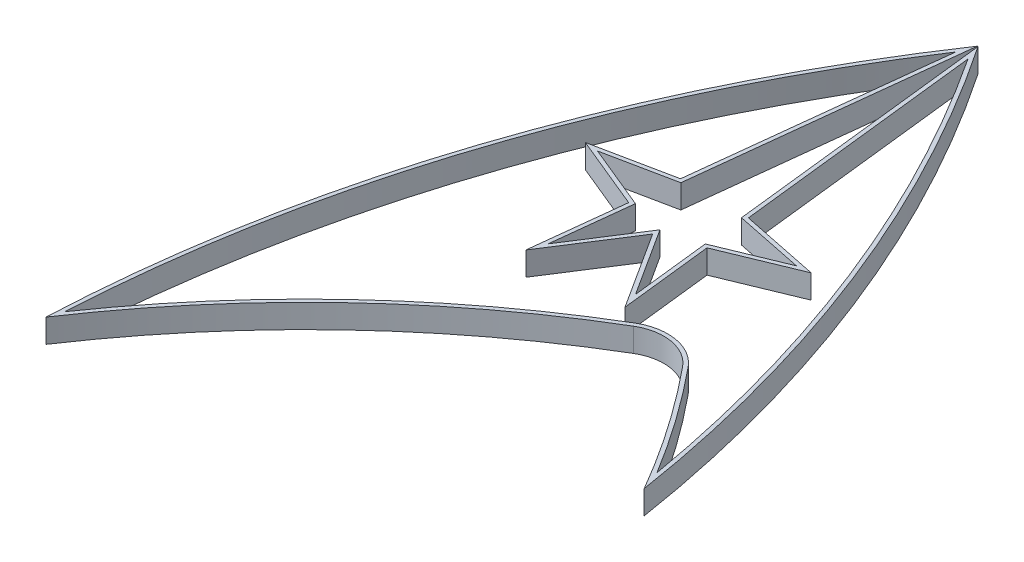
from build123d import *

# Parameters (mm, degrees)
BOSS_EXTRUDE1_DEPTH = 2.4


with BuildPart() as part:
    # Sketch2 → Boss-Extrude1 (new body)
    with BuildSketch(Plane(origin=(0, 0, 0), x_dir=(1, 0, 0), z_dir=(0, 1, 0))):
        with BuildLine():
            Line((25.28293267, 77.245611288), (22.241395548, 50.202851698))
            Line((22.241395548, 50.202851698), (15.224426897, 48.764665996))
            Line((15.224426897, 48.764665996), (21.775683691, 46.062138205))
            Line((21.775683691, 46.062138205), (20.878911595, 38.088803933))
            Line((20.878911595, 38.088803933), (25.3187138, 45.004925816))
            Line((25.3187138, 45.004925816), (29.758516004, 38.088803933))
            Line((29.758516004, 38.088803933), (28.861743908, 46.062138205))
            Line((28.861743908, 46.062138205), (35.413000702, 48.764665996))
            Line((35.413000702, 48.764665996), (28.396032051, 50.202851698))
            Line((28.396032051, 50.202851698), (25.354494929, 77.245611288))
            ThreePointArc((25.354494929, 77.245611288), (39.364716338, 50.558630658), (47.260701361, 21.470236759))
            ThreePointArc((47.260701361, 21.470236759), (43.131494569, 27.98329808), (38.487800716, 34.14011738))
            ThreePointArc((38.487800716, 34.14011738), (35.669967354, 35.788554713), (32.458155801, 35.203920598))
            ThreePointArc((32.458155801, 35.203920598), (15.517725775, 22.41503931), (1.838377838, 6.185156559))
            ThreePointArc((1.838377838, 6.185156559), (8.663390647, 43.331109422), (25.28293267, 77.245611288))
        make_face()
        with BuildLine():
            Line((28.761044533, 50.536354524), (25.936821585, 75.646941422))
            ThreePointArc((25.936821585, 75.646941422), (38.906137272, 50.63149335), (46.519959977, 23.502072134))
            ThreePointArc((46.519959977, 23.502072134), (42.849248676, 29.083132434), (38.797114504, 34.393741079))
            ThreePointArc((38.797114504, 34.393741079), (35.739465536, 36.182470951), (32.254308319, 35.548080741))
            ThreePointArc((32.254308319, 35.548080741), (15.763956049, 23.195791569), (2.309144184, 7.59198423))
            ThreePointArc((2.309144184, 7.59198423), (9.008069243, 43.099003198), (24.700606015, 75.646941422))
            Line((24.700606015, 75.646941422), (21.876383066, 50.536354524))
            Line((21.876383066, 50.536354524), (13.862415181, 48.893825592))
            Line((13.862415181, 48.893825592), (21.344500988, 45.807311742))
            Line((21.344500988, 45.807311742), (20.289917479, 36.430852681))
            Line((20.289917479, 36.430852681), (25.3187138, 44.264482803))
            Line((25.3187138, 44.264482803), (30.34751012, 36.430852681))
            Line((30.34751012, 36.430852681), (29.292926611, 45.807311742))
            Line((29.292926611, 45.807311742), (36.775012418, 48.893825592))
            Line((36.775012418, 48.893825592), (28.761044533, 50.536354524))
        make_face(mode=Mode.SUBTRACT)
    extrude(amount=BOSS_EXTRUDE1_DEPTH)


solid = part.part
